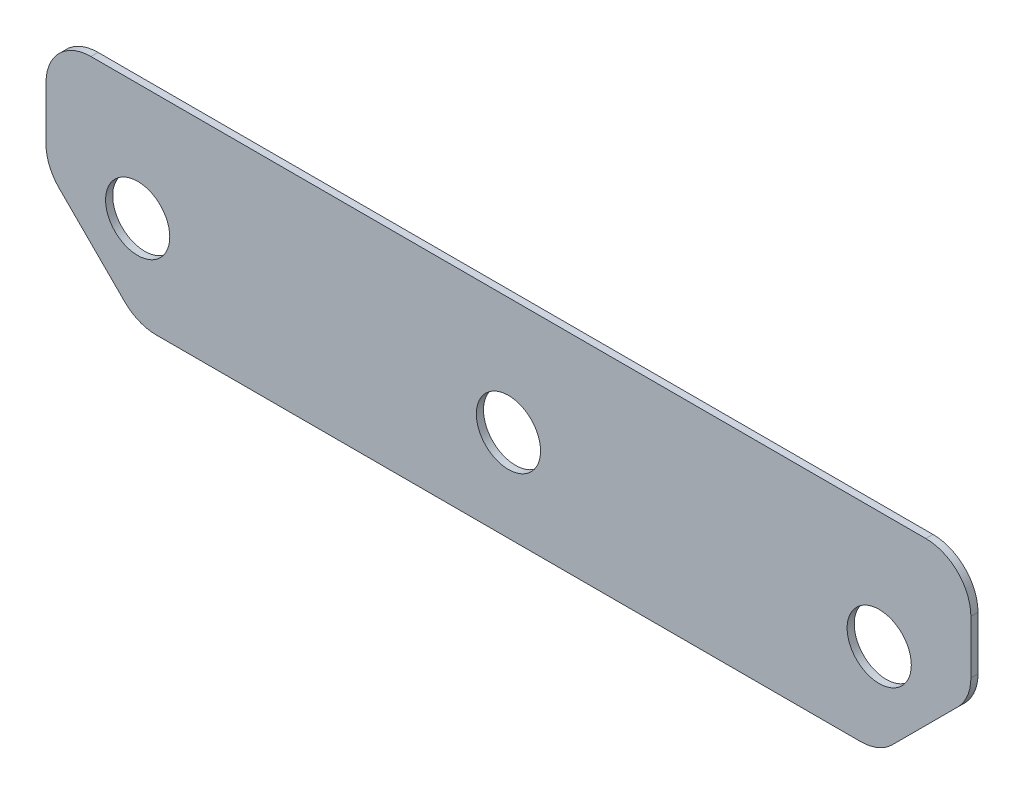
from build123d import *

# Parameters (mm, degrees)
SKETCH1_R           = 14.2875
BOSS_EXTRUDE1_DEPTH = 3.175
FILLET1_R           = 20
FILLET2_R           = 20


with BuildPart() as part:
    # Sketch1 → Boss-Extrude1 (new body)
    with BuildSketch(Plane.XY):
        with BuildLine():
            Line((-205.8238, 0), (-165.0238, -40.8))
            ThreePointArc((-165.0238, -40.8), (-136.173843328, 28.849956672), (-205.8238, 0))
        make_face()
        with Locations((-165.0238, 0)):
            Circle(SKETCH1_R, mode=Mode.SUBTRACT)
        with BuildLine():
            ThreePointArc((-205.8238, 0), (-136.173843328, 28.849956672), (-165.0238, -40.8))
            Line((-165.0238, -40.8), (-134.758308099, -40.8))
            ThreePointArc((-134.758308099, -40.8), (-119.646895144, -22.838049517), (-114.2238, 0))
            ThreePointArc((-114.2238, 0), (-149.086422549, 48.235256815), (-205.8238, 30.265491901))
            Line((-205.8238, 30.265491901), (-205.8238, 0))
        make_face()
        with BuildLine():
            ThreePointArc((-114.2238, 0), (-119.646895144, -22.838049517), (-134.758308099, -40.8))
            Line((-134.758308099, -40.8), (-30.265491901, -40.8))
            ThreePointArc((-30.265491901, -40.8), (-22.838049517, 45.376904856), (50.8, 0))
            ThreePointArc((50.8, 0), (45.376904856, -22.838049517), (30.265491901, -40.8))
            Line((30.265491901, -40.8), (134.758308099, -40.8))
            ThreePointArc((134.758308099, -40.8), (129.102775516, 35.921024484), (205.8238, 30.265491901))
            Line((205.8238, 30.265491901), (205.8238, 52))
            Line((205.8238, 52), (-205.8238, 52))
            Line((-205.8238, 52), (-205.8238, 30.265491901))
            ThreePointArc((-205.8238, 30.265491901), (-149.086422549, 48.235256815), (-114.2238, 0))
        make_face()
        with BuildLine():
            ThreePointArc((50.8, 0), (-22.838049517, 45.376904856), (-30.265491901, -40.8))
            Line((-30.265491901, -40.8), (30.265491901, -40.8))
            ThreePointArc((30.265491901, -40.8), (45.376904856, -22.838049517), (50.8, 0))
        make_face()
        Circle(SKETCH1_R, mode=Mode.SUBTRACT)
        with BuildLine():
            Line((205.8238, 0), (165.0238, -40.8))
            ThreePointArc((165.0238, -40.8), (136.173843328, 28.849956672), (205.8238, 0))
        make_face()
        with Locations((165.0238, 0)):
            Circle(SKETCH1_R, mode=Mode.SUBTRACT)
        with BuildLine():
            ThreePointArc((205.8238, 30.265491901), (129.102775516, 35.921024484), (134.758308099, -40.8))
            Line((134.758308099, -40.8), (165.0238, -40.8))
            ThreePointArc((165.0238, -40.8), (136.173843328, 28.849956672), (205.8238, 0))
            Line((205.8238, 0), (205.8238, 30.265491901))
        make_face()
    extrude(amount=BOSS_EXTRUDE1_DEPTH)

    # Fillet1
    fillet1_edges = [part.edges().sort_by_distance(p)[0] for p in [
        (-205.8238, 52, 1.5875),
        (205.8238, 52, 1.5875),
    ]]
    fillet(fillet1_edges, radius=FILLET1_R)

    # Fillet2
    fillet2_edges = [part.edges().sort_by_distance(p)[0] for p in [
        (-205.8238, 0, 1.5875),
        (205.8238, 0, 1.5875),
        (165.0238, -40.8, 1.5875),
        (-165.0238, -40.8, 1.5875),
    ]]
    fillet(fillet2_edges, radius=FILLET2_R)


solid = part.part
